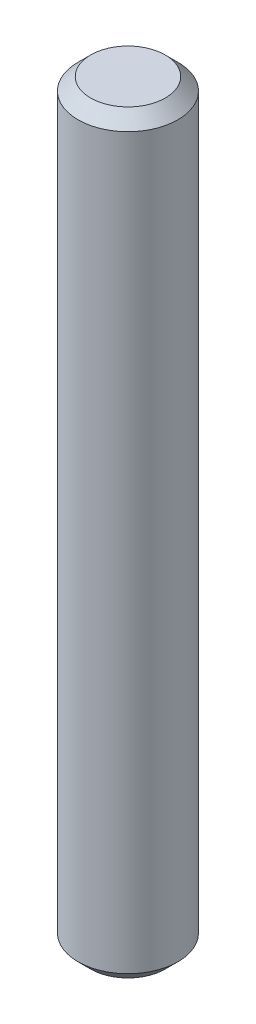
from build123d import *

# Parameters (mm, degrees)
SKETCH1_R           = 3.96875
BOSS_EXTRUDE1_DEPTH = 60
CHAMFER1_SIZE       = 1


with BuildPart() as part:
    # Sketch1 → Boss-Extrude1 (new body)
    with BuildSketch(Plane(origin=(0, 0, 0), x_dir=(1, 0, 0), z_dir=(0, 1, 0))):
        Circle(SKETCH1_R)
    extrude(amount=BOSS_EXTRUDE1_DEPTH)

    # Chamfer1
    chamfer1_edges = [part.edges().sort_by_distance(p)[0] for p in [
        (-3.96875, 0, 0),
        (-3.96875, 60, 0),
    ]]
    chamfer(chamfer1_edges, length=CHAMFER1_SIZE)


solid = part.part
